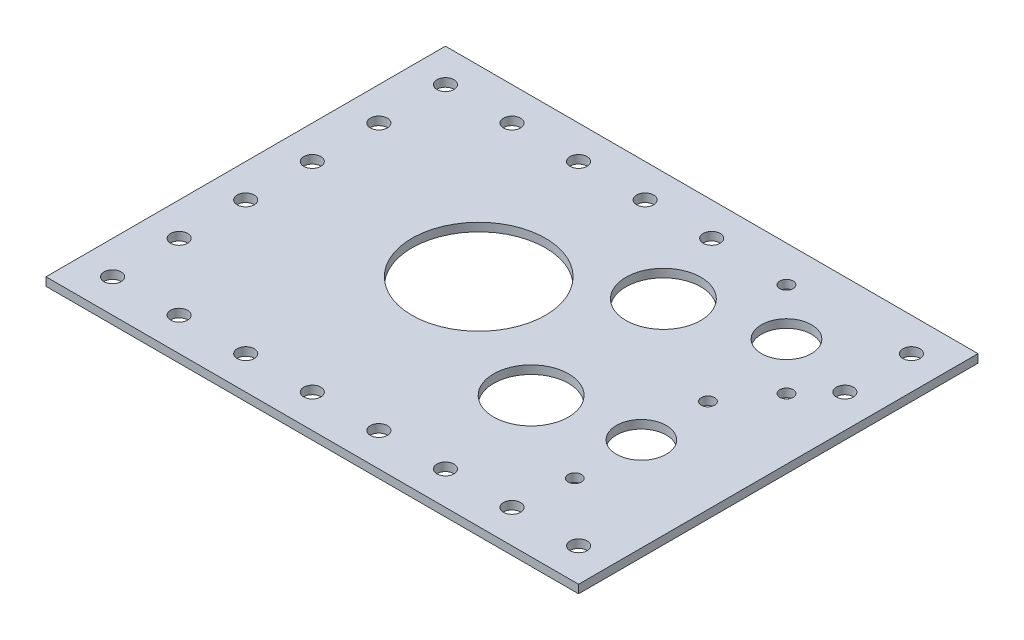
from build123d import *

# Parameters (mm, degrees)
SKETCH1_W           = 203.2
SKETCH1_H           = 152.4
BOSS_EXTRUDE1_DEPTH = 3.175
SKETCH3_R           = 3.2512
CUT_EXTRUDE4_DEPTH  = 5.08
SKETCH2_R           = 25.4762
SKETCH2_R_2         = 14.2875
SKETCH2_R_3         = 9.525
SKETCH2_R_4         = 2.54
SKETCH2_R_5         = 9.5504
CUT_EXTRUDE5_DEPTH  = 50.8


with BuildPart() as part:
    # Sketch1 → Boss-Extrude1 (new body)
    with BuildSketch(Plane(origin=(0, 0, 0), x_dir=(1, 0, 0), z_dir=(0, 1, 0))):
        with Locations((101.6, 76.2)):
            Rectangle(SKETCH1_W, SKETCH1_H)
    extrude(amount=BOSS_EXTRUDE1_DEPTH)

    # Sketch3 → Cut-Extrude4 (cut)
    with BuildSketch(Plane(origin=(0, 3.175, 0), x_dir=(1, 0, 0), z_dir=(0, 1, 0))):
        with Locations(Location((12.7, 12.7, 0), (0, 0, 270))):  # turned: the seam where the file's is
            Circle(SKETCH3_R)
        with Locations(Location((38.1, 12.7, 0), (0, 0, 270))):  # turned: the seam where the file's is
            Circle(SKETCH3_R)
        with Locations(Location((63.5, 12.7, 0), (0, 0, 270))):  # turned: the seam where the file's is
            Circle(SKETCH3_R)
        with Locations(Location((88.9, 12.7, 0), (0, 0, 270))):  # turned: the seam where the file's is
            Circle(SKETCH3_R)
        with Locations(Location((114.3, 12.7, 0), (0, 0, 270))):  # turned: the seam where the file's is
            Circle(SKETCH3_R)
        with Locations(Location((139.7, 12.7, 0), (0, 0, 270))):  # turned: the seam where the file's is
            Circle(SKETCH3_R)
        with Locations(Location((165.1, 12.7, 0), (0, 0, 270))):  # turned: the seam where the file's is
            Circle(SKETCH3_R)
        with Locations(Location((190.5, 12.7, 0), (0, 0, 270))):  # turned: the seam where the file's is
            Circle(SKETCH3_R)
        with Locations(Location((190.5, 114.3, 0), (0, 0, 270))):  # turned: the seam where the file's is
            Circle(SKETCH3_R)
        with Locations(Location((190.5, 139.7, 0), (0, 0, 270))):  # turned: the seam where the file's is
            Circle(SKETCH3_R)
        with Locations(Location((12.7, 38.1, 0), (0, 0, 270))):  # turned: the seam where the file's is
            Circle(SKETCH3_R)
        with Locations(Location((12.7, 63.5, 0), (0, 0, 270))):  # turned: the seam where the file's is
            Circle(SKETCH3_R)
        with Locations(Location((12.7, 88.9, 0), (0, 0, 270))):  # turned: the seam where the file's is
            Circle(SKETCH3_R)
        with Locations(Location((12.7, 114.3, 0), (0, 0, 270))):  # turned: the seam where the file's is
            Circle(SKETCH3_R)
        with Locations(Location((12.7, 139.7, 0), (0, 0, 270))):  # turned: the seam where the file's is
            Circle(SKETCH3_R)
        with Locations(Location((38.1, 139.7, 0), (0, 0, 270))):  # turned: the seam where the file's is
            Circle(SKETCH3_R)
        with Locations(Location((63.5, 139.7, 0), (0, 0, 270))):  # turned: the seam where the file's is
            Circle(SKETCH3_R)
        with Locations(Location((88.9, 139.7, 0), (0, 0, 270))):  # turned: the seam where the file's is
            Circle(SKETCH3_R)
        with Locations(Location((114.3, 139.7, 0), (0, 0, 270))):  # turned: the seam where the file's is
            Circle(SKETCH3_R)
    extrude(amount=-CUT_EXTRUDE4_DEPTH, mode=Mode.SUBTRACT)

    # Sketch2 → Cut-Extrude5 (cut)
    with BuildSketch(Plane(origin=(0, 3.175, 0), x_dir=(1, 0, 0), z_dir=(0, 1, 0))):
        with Locations(Location((82.55, 82.55, 0), (0, 0, 270))):  # turned: the seam where the file's is
            Circle(SKETCH2_R)
        with Locations(Location((131.7498, 53.34, 0), (0, 0, 270))):  # turned: the seam where the file's is
            Circle(SKETCH2_R_2)
        with Locations(Location((167.4622, 59.69, 0), (0, 0, 270))):  # turned: the seam where the file's is
            Circle(SKETCH2_R_3)
        with Locations(Location((167.4622, 34.29, 0), (0, 0, 270))):  # turned: the seam where the file's is
            Circle(SKETCH2_R_4)
        with Locations(Location((167.4622, 85.09, 0), (0, 0, 270))):  # turned: the seam where the file's is
            Circle(SKETCH2_R_4)
        with Locations(Location((125.0696, 110.49, 0), (0, 0, 270))):  # turned: the seam where the file's is
            Circle(SKETCH2_R_2)
        with Locations(Location((161.8742, 120.65, 0), (0, 0, 270))):  # turned: the seam where the file's is
            Circle(SKETCH2_R_5)
        with Locations(Location((179.832, 102.6922, 0), (0, 0, 270))):  # turned: the seam where the file's is
            Circle(SKETCH2_R_4)
        with Locations(Location((143.9164, 138.6078, 0), (0, 0, 270))):  # turned: the seam where the file's is
            Circle(SKETCH2_R_4)
    extrude(amount=-CUT_EXTRUDE5_DEPTH, mode=Mode.SUBTRACT)


solid = part.part
